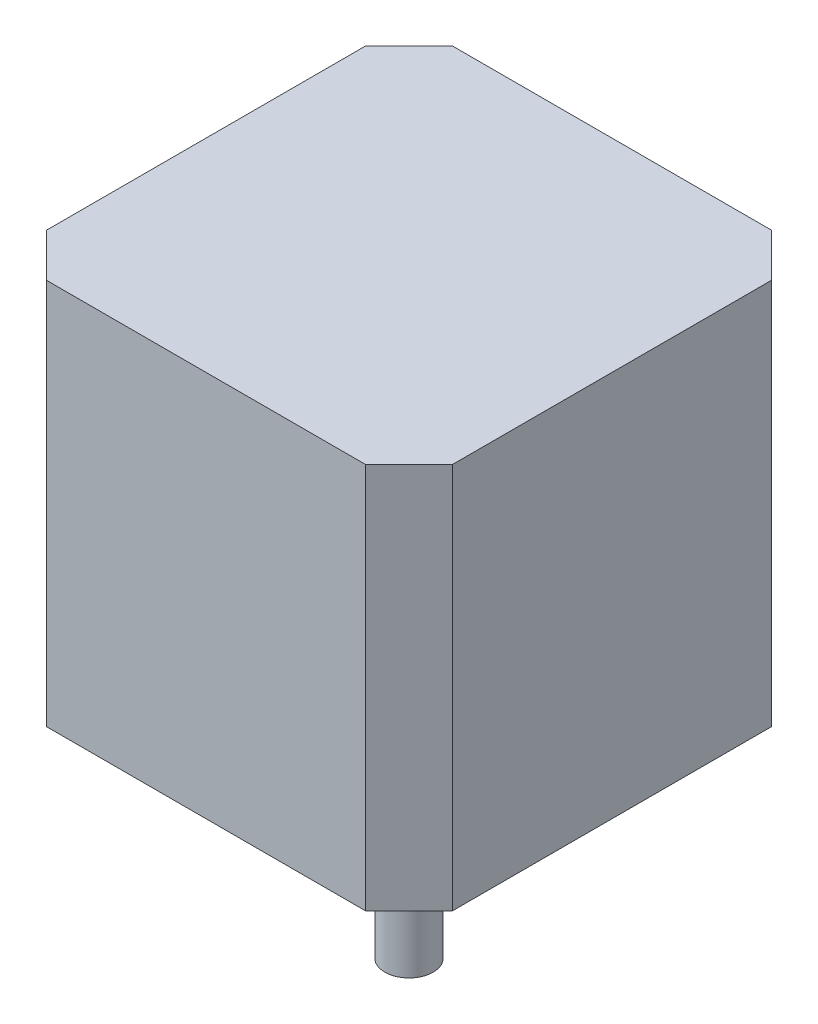
from build123d import *

# Parameters (mm, degrees)
SKETCH1_W                 = 42
SKETCH1_H                 = 42
BOSS_EXTRUDE1_DEPTH       = 40
SKETCH2_R                 = 11
BOSS_EXTRUDE2_DEPTH       = 2
SKETCH3_R                 = 2.5
BOSS_EXTRUDE3_DEPTH       = 21
CHAMFER1_SIZE             = 4.5
M3X0_5_TAPPED_HOLE2_D     = 2.5
M3X0_5_TAPPED_HOLE2_DEPTH = 6
M3X0_5_TAPPED_HOLE2_TIP   = 0.751075774


with BuildPart() as part:
    # Sketch1 → Boss-Extrude1 (new body)
    with BuildSketch(Plane(origin=(0, 0, 0), x_dir=(1, 0, 0), z_dir=(0, 1, 0))):
        Rectangle(SKETCH1_W, SKETCH1_H)
    extrude(amount=BOSS_EXTRUDE1_DEPTH)

    # Sketch2 → Boss-Extrude2 (add)
    with BuildSketch(Plane.XZ):
        Circle(SKETCH2_R)
    extrude(amount=BOSS_EXTRUDE2_DEPTH)

    # Sketch3 → Boss-Extrude3 (add)
    with BuildSketch(Plane.XZ.offset(2)):
        Circle(SKETCH3_R)
    extrude(amount=BOSS_EXTRUDE3_DEPTH)

    # Chamfer1
    chamfer1_edges = [part.edges().sort_by_distance(p)[0] for p in [
        (-21, 20, 21),
        (-21, 20, -21),
        (21, 20, -21),
        (21, 20, 21),
    ]]
    chamfer(chamfer1_edges, length=CHAMFER1_SIZE)

    # M3x0.5 Tapped Hole2
    with Locations(Plane(origin=(0, 0, 0), x_dir=(-1, 0, 0), z_dir=(0, -1, 0))):
        with Locations((15.5, 15.5), (-15.5, 15.5), (-15.5, -15.5), (15.5, -15.5)):
            Hole(M3X0_5_TAPPED_HOLE2_D / 2, depth=M3X0_5_TAPPED_HOLE2_DEPTH)
            with Locations((0, 0, -(M3X0_5_TAPPED_HOLE2_DEPTH + M3X0_5_TAPPED_HOLE2_TIP / 2))):  # 118° drill point
                Cone(0, M3X0_5_TAPPED_HOLE2_D / 2, M3X0_5_TAPPED_HOLE2_TIP, mode=Mode.SUBTRACT)


solid = part.part
